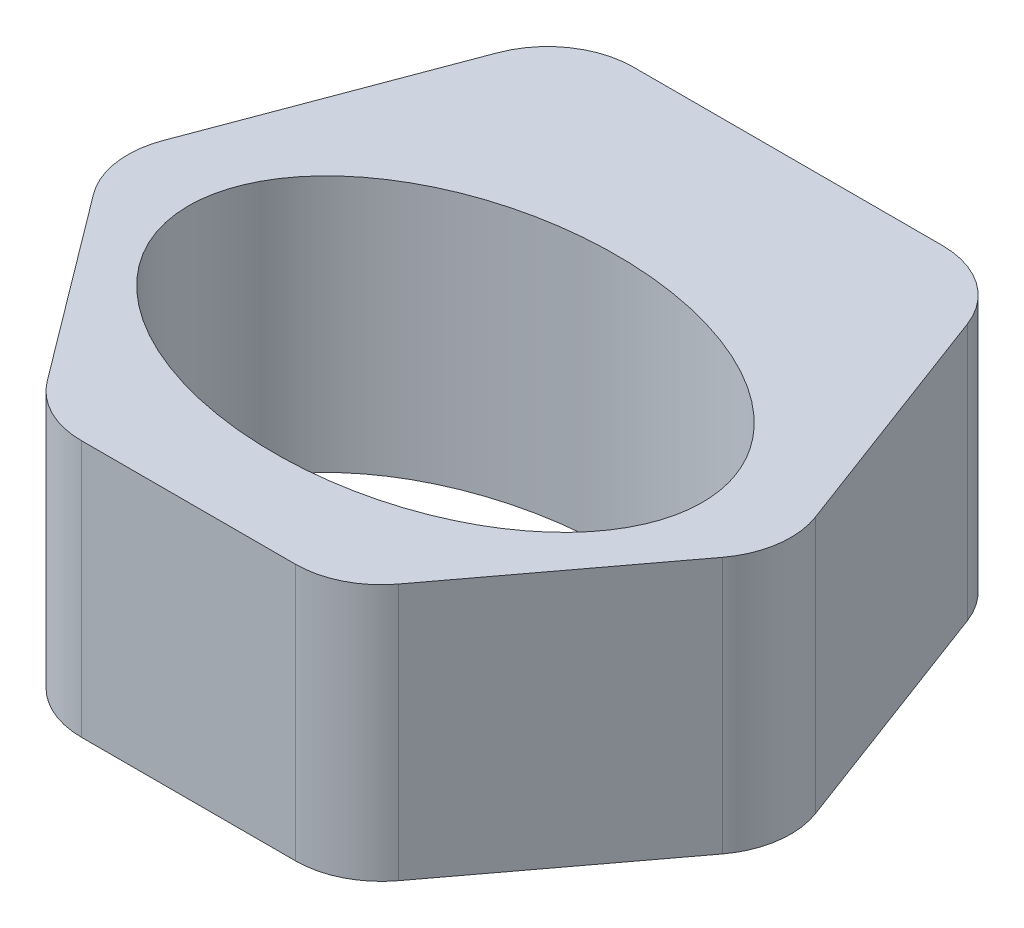
from build123d import *

# Parameters (mm, degrees)
SKETCH1_RX          = 30
SKETCH1_RY          = 20
BOSS_EXTRUDE1_DEPTH = 30
FILLET1_R           = 10


with BuildPart() as part:
    # Sketch1 → Boss-Extrude1 (new body)
    with BuildSketch(Plane(origin=(0, 0, 0), x_dir=(1, 0, 0), z_dir=(0, 1, 0))):
        Polygon((25, 40), (-25, 40), (-40, 0), (-17.5, -30), (17.5, -30), (40, 0), align=None)
        with Locations(Location((0, 0), (0, 0, -180))):
            Ellipse(SKETCH1_RX, SKETCH1_RY, mode=Mode.SUBTRACT)
    extrude(amount=BOSS_EXTRUDE1_DEPTH)

    # Fillet1
    fillet1_edges = [part.edges().sort_by_distance(p)[0] for p in [
        (-25, 15, -40),
        (25, 15, -40),
        (40, 15, 0),
        (17.5, 15, 30),
        (-17.5, 15, 30),
        (-40, 15, 0),
    ]]
    fillet(fillet1_edges, radius=FILLET1_R)


solid = part.part
